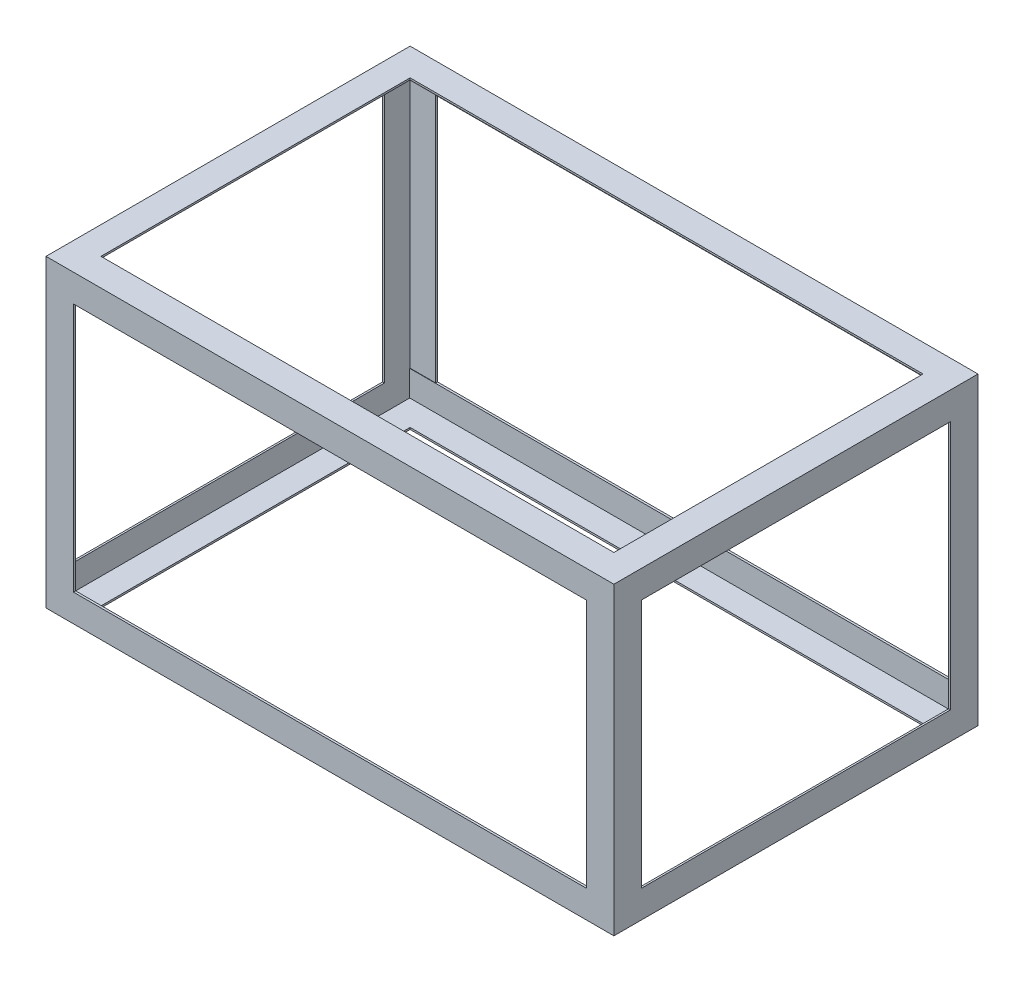
from build123d import *

# Parameters (mm, degrees)
BOSS_EXTRUDE1_DEPTH   = 1574.8
BOSS_EXTRUDE1_2_DEPTH = 1574.8
BOSS_EXTRUDE1_3_DEPTH = 1574.8
BOSS_EXTRUDE1_4_DEPTH = 1574.8
BOSS_EXTRUDE2_START   = -498.751917
BOSS_EXTRUDE2_DEPTH   = 997.503834
BOSS_EXTRUDE3_REACH   = 846.55


with BuildPart() as part:
    # Sketch2 → Boss-Extrude1 (new body)
    with BuildSketch(Plane(origin=(0, 0, 0), x_dir=(0, 0, -1), z_dir=(1, 0, 0))):
        Polygon((-504.825, -346.075), (-504.825, -422.275), (-428.625, -422.275), (-428.625, -417.195), (-498.751917293, -417.195), (-498.751917293, -346.075), align=None)
    extrude(amount=BOSS_EXTRUDE1_DEPTH)



with BuildPart() as body_2:
    # Sketch2 → Boss-Extrude1 2 (new body)
    with BuildSketch(Plane(origin=(0, 0, 0), x_dir=(0, 0, -1), z_dir=(1, 0, 0))):
        Polygon((498.751917293, -417.195), (498.751917293, -346.075), (504.825, -346.075), (504.825, -422.275), (428.625, -422.275), (428.625, -417.195), align=None)
    extrude(amount=BOSS_EXTRUDE1_2_DEPTH)


with BuildPart() as body_3:
    # Sketch2 → Boss-Extrude1 3 (new body)
    with BuildSketch(Plane(origin=(0, 0, 0), x_dir=(0, 0, -1), z_dir=(1, 0, 0))):
        Polygon((428.625, 417.195), (498.751917293, 417.195), (498.751917293, 346.075), (504.825, 346.075), (504.825, 422.275), (428.625, 422.275), align=None)
    extrude(amount=BOSS_EXTRUDE1_3_DEPTH)


with BuildPart() as body_4:
    # Sketch2 → Boss-Extrude1 4 (new body)
    with BuildSketch(Plane(origin=(0, 0, 0), x_dir=(0, 0, -1), z_dir=(1, 0, 0))):
        Polygon((-498.751917293, 417.195), (-498.751917293, 346.075), (-504.825, 346.075), (-504.825, 422.275), (-428.625, 422.275), (-428.625, 417.195), align=None)
    extrude(amount=BOSS_EXTRUDE1_4_DEPTH)


with BuildPart() as part_1:
    add(part.part)

    add(body_2.part)  # Boss-Extrude2 merges body 2

    add(body_3.part)  # Boss-Extrude2 merges body 3

    add(body_4.part)  # Boss-Extrude2 merges body 4
    # Sketch3 → Boss-Extrude2 (add)
    with BuildSketch(Plane.XY.offset(BOSS_EXTRUDE2_START)):
        Polygon((0, -422.275), (0, -346.075), (5.08, -346.075), (5.08, -417.195), (76.2, -417.195), (76.2, -422.275), align=None)
        Polygon((76.2, 422.275), (0, 422.275), (0, 346.075), (5.08, 346.075), (5.08, 417.195), (76.2, 417.195), align=None)
        Polygon((1574.8, 422.275), (1574.8, 346.075), (1569.72, 346.075), (1569.72, 417.195), (1498.6, 417.195), (1498.6, 422.275), align=None)
        Polygon((1498.6, -422.275), (1574.8, -422.275), (1574.8, -346.075), (1569.72, -346.075), (1569.72, -417.195), (1498.6, -417.195), align=None)
    extrude(amount=BOSS_EXTRUDE2_DEPTH)

    # Sketch4 → Boss-Extrude3 (add, up to next)
    with BuildSketch(Plane(origin=(0, 422.275, 0), x_dir=(1, 0, 0), z_dir=(0, 1, 0)), mode=Mode.PRIVATE) as boss_extrude3_sk1:
        Polygon((0, 504.825), (0, 428.625), (5.08, 428.625), (5.08, 499.745), (76.2, 499.745), (76.2, 504.825), align=None)
    boss_extrude3_tool1 = extrude(boss_extrude3_sk1.sketch, amount=-BOSS_EXTRUDE3_REACH, mode=Mode.PRIVATE) - part_1.part
    add(boss_extrude3_tool1.solids().sort_by_distance((1.077631, 422.275, -466.725))[0])
    # Sketch4 → Boss-Extrude3 (add, up to next)
    with BuildSketch(Plane(origin=(0, 422.275, 0), x_dir=(1, 0, 0), z_dir=(0, 1, 0)), mode=Mode.PRIVATE) as boss_extrude3_sk2:
        Polygon((76.2, -504.825), (0, -504.825), (0, -428.625), (5.08, -428.625), (5.08, -499.745), (76.2, -499.745), align=None)
    boss_extrude3_tool2 = extrude(boss_extrude3_sk2.sketch, amount=-BOSS_EXTRUDE3_REACH, mode=Mode.PRIVATE) - part_1.part
    add(boss_extrude3_tool2.solids().sort_by_distance((38.1, 422.275, 503.747369))[0])
    # Sketch4 → Boss-Extrude3 (add, up to next)
    with BuildSketch(Plane(origin=(0, 422.275, 0), x_dir=(1, 0, 0), z_dir=(0, 1, 0)), mode=Mode.PRIVATE) as boss_extrude3_sk3:
        Polygon((1574.8, -504.825), (1574.8, -428.625), (1569.72, -428.625), (1569.72, -499.745), (1498.6, -499.745), (1498.6, -504.825), align=None)
    boss_extrude3_tool3 = extrude(boss_extrude3_sk3.sketch, amount=-BOSS_EXTRUDE3_REACH, mode=Mode.PRIVATE) - part_1.part
    add(boss_extrude3_tool3.solids().sort_by_distance((1573.722369, 422.275, 466.725))[0])
    # Sketch4 → Boss-Extrude3 (add, up to next)
    with BuildSketch(Plane(origin=(0, 422.275, 0), x_dir=(1, 0, 0), z_dir=(0, 1, 0)), mode=Mode.PRIVATE) as boss_extrude3_sk4:
        Polygon((1498.6, 504.825), (1574.8, 504.825), (1574.8, 428.625), (1569.72, 428.625), (1569.72, 499.745), (1498.6, 499.745), align=None)
    boss_extrude3_tool4 = extrude(boss_extrude3_sk4.sketch, amount=-BOSS_EXTRUDE3_REACH, mode=Mode.PRIVATE) - part_1.part
    add(boss_extrude3_tool4.solids().sort_by_distance((1536.7, 422.275, -503.747369))[0])


solid = part_1.part
